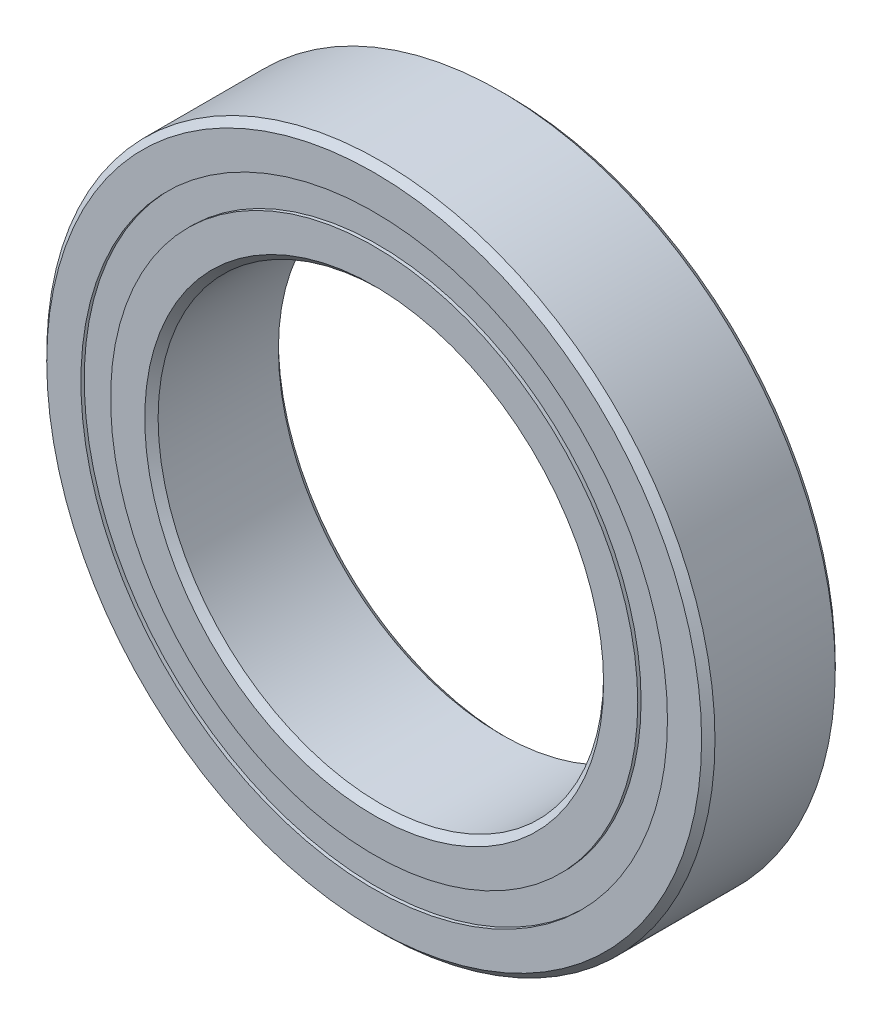
from build123d import *

# Parameters (mm, degrees)
CIRPATTERN1_COUNT = 25
SKETCH5_W         = 0.679644008
SKETCH5_H         = 0.666666666


with BuildPart() as part:
    # Sketch1 → Revolve1 (revolve)
    with BuildSketch(Plane(origin=(0, 0, 0), x_dir=(0, 0, -1), z_dir=(1, 0, 0))):
        with BuildLine():
            Line((1.35, 7.5), (-1.35, 7.5))
            Line((-1.35, 7.5), (-1.5, 7.35))
            Line((-1.5, 7.35), (-1.5, 6.583333333))
            Line((-1.5, 6.583333333), (-0.666666667, 6.583333333))
            ThreePointArc((-0.666666667, 6.583333333), (0, 6.995355992), (0.666666667, 6.583333333))
            Line((0.666666667, 6.583333333), (1.5, 6.583333333))
            Line((1.5, 6.583333333), (1.5, 7.35))
            Line((1.5, 7.35), (1.35, 7.5))
        make_face()
    revolve(axis=Axis((0, 0, 1.5), (0, 0, -1)))


with BuildPart() as body_2:
    # Sketch2 → Revolve2 (revolve)
    with BuildSketch(Plane(origin=(0, 0, 0), x_dir=(0, 0, -1), z_dir=(1, 0, 0))):
        with BuildLine():
            Line((-1.5, 5.916666667), (-0.666666667, 5.916666667))
            ThreePointArc((-0.666666667, 5.916666667), (0, 5.504644008), (0.666666667, 5.916666667))
            Line((0.666666667, 5.916666667), (1.5, 5.916666667))
            Line((1.5, 5.916666667), (1.5, 5.15))
            Line((1.5, 5.15), (1.35, 5))
            Line((1.35, 5), (-1.35, 5))
            Line((-1.35, 5), (-1.5, 5.15))
            Line((-1.5, 5.15), (-1.5, 5.916666667))
        make_face()
    revolve(axis=Axis((0, 0, 1.5), (0, 0, -1)))


with BuildPart() as body_3:
    # Sketch3 → Revolve3 (revolve)
    with BuildSketch(Plane(origin=(0, 0, 0), x_dir=(0, 0, -1), z_dir=(1, 0, 0))):
        with BuildLine():
            Line((-0.745355992, 6.25), (0.745355992, 6.25))
            ThreePointArc((0.745355992, 6.25), (0, 6.995355992), (-0.745355992, 6.25))
        make_face()
    revolve(axis=Axis((0, 6.25, 0.745355992), (0, 0, -1)))


with BuildPart() as cirpattern1_1:
    # CirPattern1: pattern copy
    add(body_3.part.rotate(Axis((0, 0, -1.5), (0, 0, 1)), 1 * 360 / CIRPATTERN1_COUNT))


with BuildPart() as cirpattern1_2:
    # CirPattern1: pattern copy
    add(body_3.part.rotate(Axis((0, 0, -1.5), (0, 0, 1)), 2 * 360 / CIRPATTERN1_COUNT))


with BuildPart() as cirpattern1_3:
    # CirPattern1: pattern copy
    add(body_3.part.rotate(Axis((0, 0, -1.5), (0, 0, 1)), 3 * 360 / CIRPATTERN1_COUNT))


with BuildPart() as cirpattern1_4:
    # CirPattern1: pattern copy
    add(body_3.part.rotate(Axis((0, 0, -1.5), (0, 0, 1)), 4 * 360 / CIRPATTERN1_COUNT))


with BuildPart() as cirpattern1_5:
    # CirPattern1: pattern copy
    add(body_3.part.rotate(Axis((0, 0, -1.5), (0, 0, 1)), 5 * 360 / CIRPATTERN1_COUNT))


with BuildPart() as cirpattern1_6:
    # CirPattern1: pattern copy
    add(body_3.part.rotate(Axis((0, 0, -1.5), (0, 0, 1)), 6 * 360 / CIRPATTERN1_COUNT))


with BuildPart() as cirpattern1_7:
    # CirPattern1: pattern copy
    add(body_3.part.rotate(Axis((0, 0, -1.5), (0, 0, 1)), 7 * 360 / CIRPATTERN1_COUNT))


with BuildPart() as cirpattern1_8:
    # CirPattern1: pattern copy
    add(body_3.part.rotate(Axis((0, 0, -1.5), (0, 0, 1)), 8 * 360 / CIRPATTERN1_COUNT))


with BuildPart() as cirpattern1_9:
    # CirPattern1: pattern copy
    add(body_3.part.rotate(Axis((0, 0, -1.5), (0, 0, 1)), 9 * 360 / CIRPATTERN1_COUNT))


with BuildPart() as cirpattern1_10:
    # CirPattern1: pattern copy
    add(body_3.part.rotate(Axis((0, 0, -1.5), (0, 0, 1)), 10 * 360 / CIRPATTERN1_COUNT))


with BuildPart() as cirpattern1_11:
    # CirPattern1: pattern copy
    add(body_3.part.rotate(Axis((0, 0, -1.5), (0, 0, 1)), 11 * 360 / CIRPATTERN1_COUNT))


with BuildPart() as cirpattern1_12:
    # CirPattern1: pattern copy
    add(body_3.part.rotate(Axis((0, 0, -1.5), (0, 0, 1)), 12 * 360 / CIRPATTERN1_COUNT))


with BuildPart() as cirpattern1_13:
    # CirPattern1: pattern copy
    add(body_3.part.rotate(Axis((0, 0, -1.5), (0, 0, 1)), 13 * 360 / CIRPATTERN1_COUNT))


with BuildPart() as cirpattern1_14:
    # CirPattern1: pattern copy
    add(body_3.part.rotate(Axis((0, 0, -1.5), (0, 0, 1)), 14 * 360 / CIRPATTERN1_COUNT))


with BuildPart() as cirpattern1_15:
    # CirPattern1: pattern copy
    add(body_3.part.rotate(Axis((0, 0, -1.5), (0, 0, 1)), 15 * 360 / CIRPATTERN1_COUNT))


with BuildPart() as cirpattern1_16:
    # CirPattern1: pattern copy
    add(body_3.part.rotate(Axis((0, 0, -1.5), (0, 0, 1)), 16 * 360 / CIRPATTERN1_COUNT))


with BuildPart() as cirpattern1_17:
    # CirPattern1: pattern copy
    add(body_3.part.rotate(Axis((0, 0, -1.5), (0, 0, 1)), 17 * 360 / CIRPATTERN1_COUNT))


with BuildPart() as cirpattern1_18:
    # CirPattern1: pattern copy
    add(body_3.part.rotate(Axis((0, 0, -1.5), (0, 0, 1)), 18 * 360 / CIRPATTERN1_COUNT))


with BuildPart() as cirpattern1_19:
    # CirPattern1: pattern copy
    add(body_3.part.rotate(Axis((0, 0, -1.5), (0, 0, 1)), 19 * 360 / CIRPATTERN1_COUNT))


with BuildPart() as cirpattern1_20:
    # CirPattern1: pattern copy
    add(body_3.part.rotate(Axis((0, 0, -1.5), (0, 0, 1)), 20 * 360 / CIRPATTERN1_COUNT))


with BuildPart() as cirpattern1_21:
    # CirPattern1: pattern copy
    add(body_3.part.rotate(Axis((0, 0, -1.5), (0, 0, 1)), 21 * 360 / CIRPATTERN1_COUNT))


with BuildPart() as cirpattern1_22:
    # CirPattern1: pattern copy
    add(body_3.part.rotate(Axis((0, 0, -1.5), (0, 0, 1)), 22 * 360 / CIRPATTERN1_COUNT))


with BuildPart() as cirpattern1_23:
    # CirPattern1: pattern copy
    add(body_3.part.rotate(Axis((0, 0, -1.5), (0, 0, 1)), 23 * 360 / CIRPATTERN1_COUNT))


with BuildPart() as cirpattern1_24:
    # CirPattern1: pattern copy
    add(body_3.part.rotate(Axis((0, 0, -1.5), (0, 0, 1)), 24 * 360 / CIRPATTERN1_COUNT))


with BuildPart() as body_28:
    # Sketch5 → Revolve5 (revolve)
    with BuildSketch(Plane(origin=(0, 0, 0), x_dir=(0, 0, -1), z_dir=(1, 0, 0))):
        with Locations((-1.085177996, 6.25)):
            Rectangle(SKETCH5_W, SKETCH5_H)
        with Locations((1.085177996, 6.25)):
            Rectangle(SKETCH5_W, SKETCH5_H)
    revolve(axis=Axis((0, 0, 1.5), (0, 0, -1)))


solid = Compound([part.part, body_2.part, body_3.part, cirpattern1_1.part, cirpattern1_2.part, cirpattern1_3.part, cirpattern1_4.part, cirpattern1_5.part, cirpattern1_6.part, cirpattern1_7.part, cirpattern1_8.part, cirpattern1_9.part, cirpattern1_10.part, cirpattern1_11.part, cirpattern1_12.part, cirpattern1_13.part, cirpattern1_14.part, cirpattern1_15.part, cirpattern1_16.part, cirpattern1_17.part, cirpattern1_18.part, cirpattern1_19.part, cirpattern1_20.part, cirpattern1_21.part, cirpattern1_22.part, cirpattern1_23.part, cirpattern1_24.part, body_28.part])
